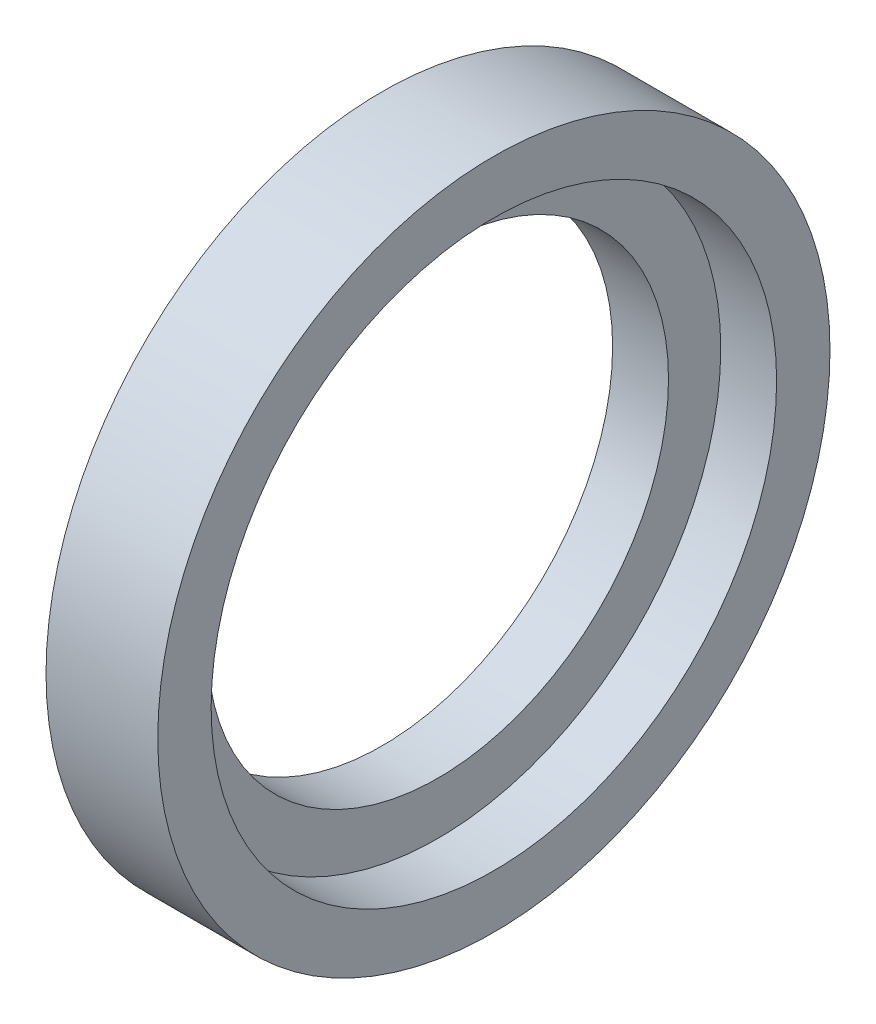
from build123d import *

# Parameters (mm, degrees)
SKETCH1_R           = 30.075
SKETCH1_R_2         = 20.625
BOSS_EXTRUDE1_DEPTH = 10
SKETCH2_R           = 25.3
CUT_EXTRUDE1_DEPTH  = 5


with BuildPart() as part:
    # Sketch1 → Boss-Extrude1 (new body)
    with BuildSketch(Plane(origin=(0, 0, 0), x_dir=(0, 0, -1), z_dir=(1, 0, 0))):
        Circle(SKETCH1_R)
        Circle(SKETCH1_R_2, mode=Mode.SUBTRACT)
    extrude(amount=BOSS_EXTRUDE1_DEPTH)

    # Sketch2 → Cut-Extrude1 (cut)
    with BuildSketch(Plane(origin=(10, 0, 0), x_dir=(0, 0, -1), z_dir=(1, 0, 0))):
        Circle(SKETCH2_R)
    extrude(amount=-CUT_EXTRUDE1_DEPTH, mode=Mode.SUBTRACT)


solid = part.part
